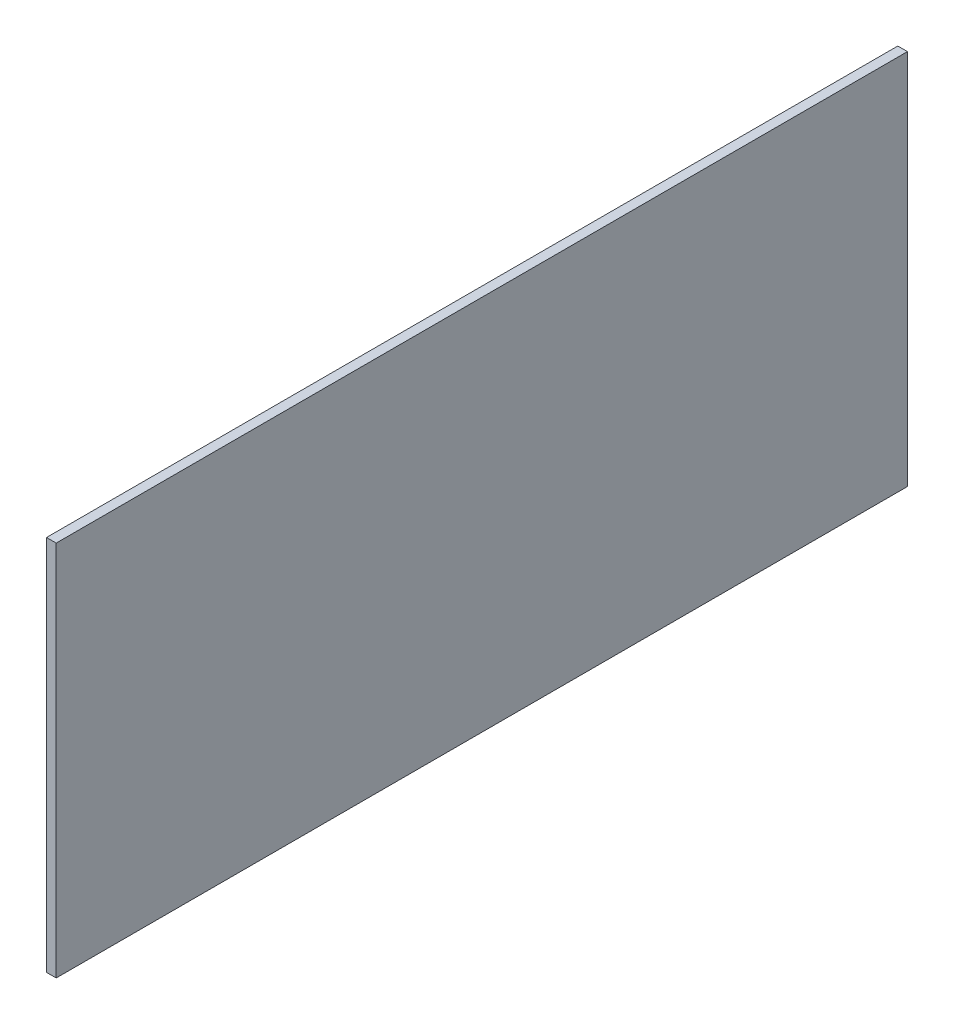
from build123d import *

# Parameters (mm, degrees)
SKETCH_1_W      = 1582
SKETCH_1_H      = 700
EXTRUDE_1_DEPTH = 18


with BuildPart() as part:
    # Эскиз1 → Бобышка-Вытянуть1 (new body)
    with BuildSketch(Plane(origin=(0, 0, 0), x_dir=(0, 0, -1), z_dir=(1, 0, 0))):
        with Locations((520.891528929, 59.349151892)):
            Rectangle(SKETCH_1_W, SKETCH_1_H)
    extrude(amount=EXTRUDE_1_DEPTH)


solid = part.part
